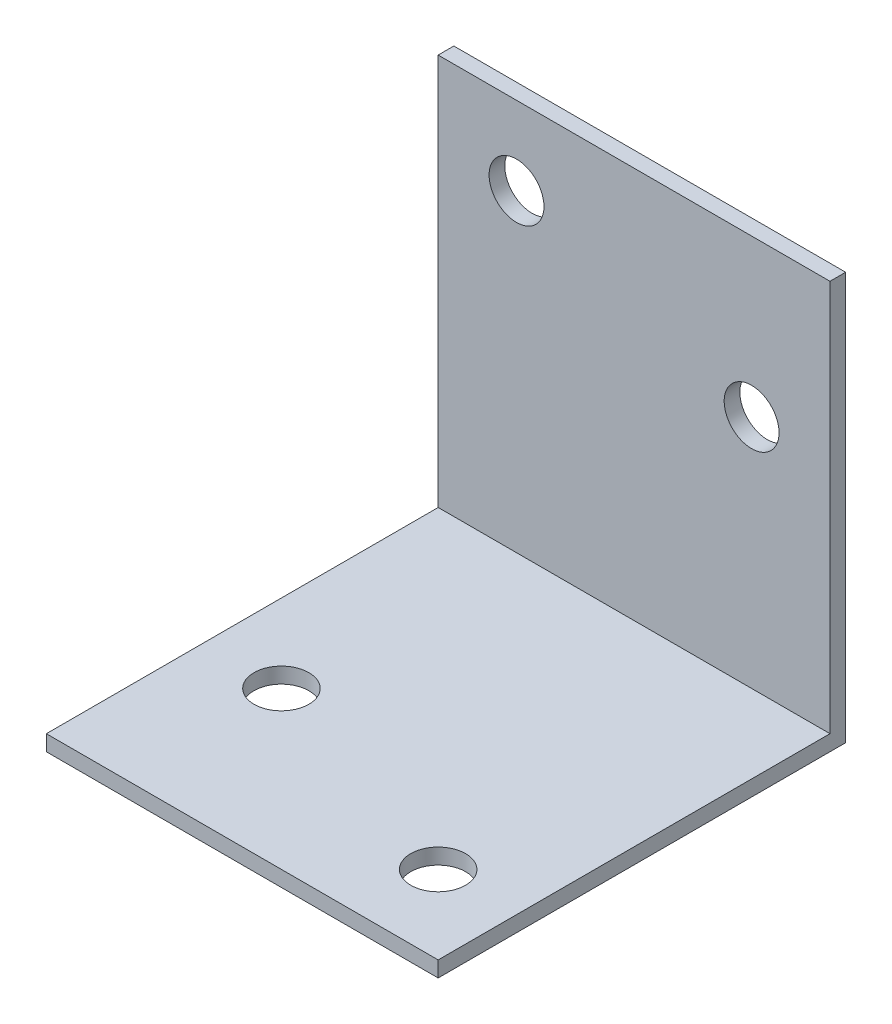
from build123d import *

# Parameters (mm, degrees)
SKETCH1_W           = 25
SKETCH1_H           = 25
SKETCH1_R           = 1.75
BOSS_EXTRUDE2_DEPTH = 1
SKETCH4_W           = 25
SKETCH4_H           = 26
SKETCH4_R           = 1.75
BOSS_EXTRUDE3_DEPTH = 1


with BuildPart() as part:
    # Sketch1 → Boss-Extrude2 (new body)
    with BuildSketch(Plane.XY):
        Rectangle(SKETCH1_W, SKETCH1_H)
        with Locations((7.5, 2.5)):
            Circle(SKETCH1_R, mode=Mode.SUBTRACT)
        with Locations((-7.5, 7.5)):
            Circle(SKETCH1_R, mode=Mode.SUBTRACT)
    extrude(amount=BOSS_EXTRUDE2_DEPTH)

    # Sketch4 → Boss-Extrude3 (add)
    with BuildSketch(Plane.XZ.offset(12.5)):
        with Locations((0, 13)):
            Rectangle(SKETCH4_W, SKETCH4_H)
        with Locations((7.5, 21)):
            Circle(SKETCH4_R, mode=Mode.SUBTRACT)
        with Locations((-7.5, 16)):
            Circle(SKETCH4_R, mode=Mode.SUBTRACT)
    extrude(amount=BOSS_EXTRUDE3_DEPTH)


solid = part.part
